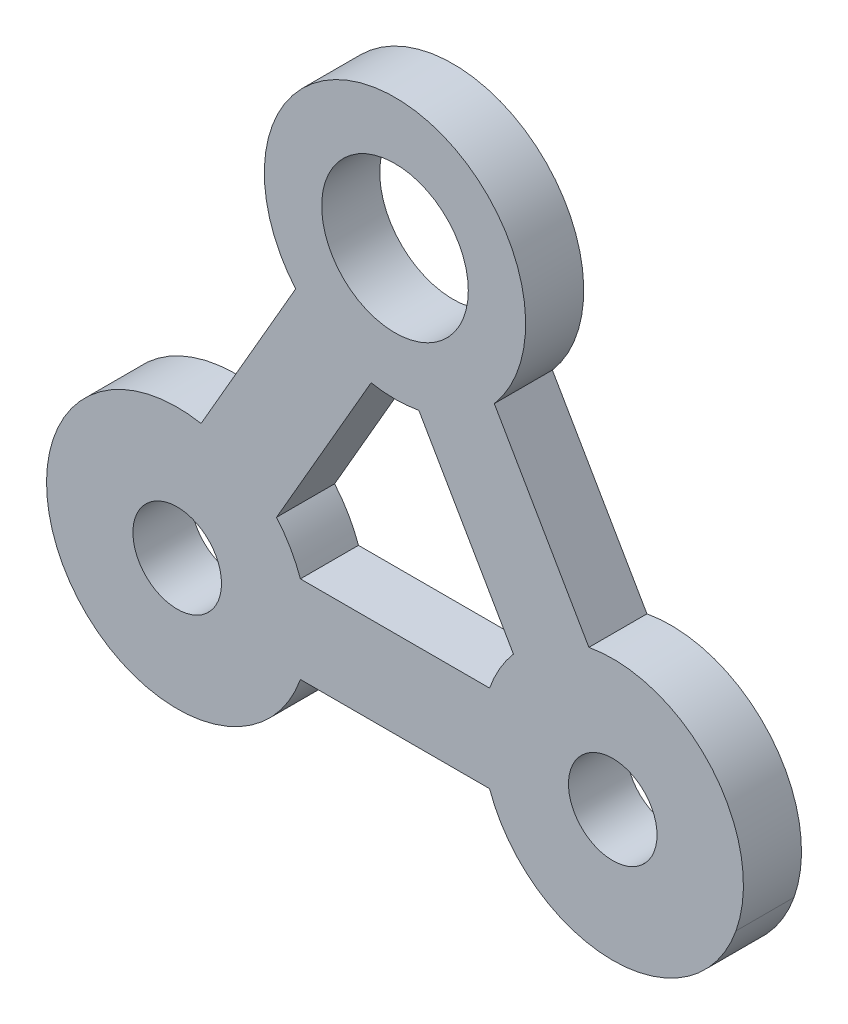
from build123d import *

# Parameters (mm, degrees)
SKETCH_1_R      = 3.05
SKETCH_1_R_2    = 5.05
EXTRUDE_1_DEPTH = 4


with BuildPart() as part:
    # 草图1 → 凸台-拉伸1 (new body)
    with BuildSketch(Plane.XY):
        with BuildLine():
            Line((8.424446615, -21.943763958), (1.909734407, -10.659930534))
            ThreePointArc((1.909734407, -10.659930534), (-4.930907825, 4.188585667), (-11.771663917, -10.659878079))
            Line((-11.771663917, -10.659878079), (-18.286394211, -21.943701062))
            ThreePointArc((-18.286394211, -21.943701062), (-23.683045573, -22.611553889), (-27.70998166, -26.265819763))
            Line((-27.70998166, -26.265819763), (-27.725209001, -26.292194242))
            ThreePointArc((-27.725209001, -26.292194242), (-28.893024381, -31.617931514), (-26.77174103, -36.640622744))
            ThreePointArc((-26.77174103, -36.640622744), (-18.28646206, -39.640629543), (-11.445740476, -33.792165797))
            Line((-11.445740476, -33.792165797), (1.583702026, -33.792176239))
            ThreePointArc((1.583702026, -33.792176239), (4.862729341, -38.133535764), (10.044259423, -39.792200488))
            Line((10.044259423, -39.792200488), (10.069016027, -39.792200488))
            ThreePointArc((10.069016027, -39.792200488), (15.265142091, -38.140688354), (18.55427588, -33.792261359))
            ThreePointArc((18.55427588, -33.792261359), (16.909732497, -24.943778842), (8.424446615, -21.943763958))
        make_face()
        with Locations((10.069016027, -30.792200488)):
            Circle(SKETCH_1_R, mode=Mode.SUBTRACT)
        with Locations((-4.930942332, -4.811414333)):
            Circle(SKETCH_1_R_2, mode=Mode.SUBTRACT)
        with Locations((-19.930983973, -30.792200488)):
            Circle(SKETCH_1_R, mode=Mode.SUBTRACT)
        with BuildLine():
            Line((-3.286438615, -13.659894854), (3.228291788, -24.943759794))
            ThreePointArc((3.228291788, -24.943759794), (2.274792619, -26.292204621), (1.583743226, -27.792176239))
            Line((1.583743226, -27.792176239), (-11.445735667, -27.792165797))
            ThreePointArc((-11.445735667, -27.792165797), (-12.136773559, -26.29218888), (-13.090262388, -24.943736742))
            Line((-13.090262388, -24.943736742), (-6.575513898, -13.659882243))
            ThreePointArc((-6.575513898, -13.659882243), (-4.930976838, -13.811414333), (-3.286438615, -13.659894854))
        make_face(mode=Mode.SUBTRACT)
    extrude(amount=EXTRUDE_1_DEPTH)


solid = part.part
